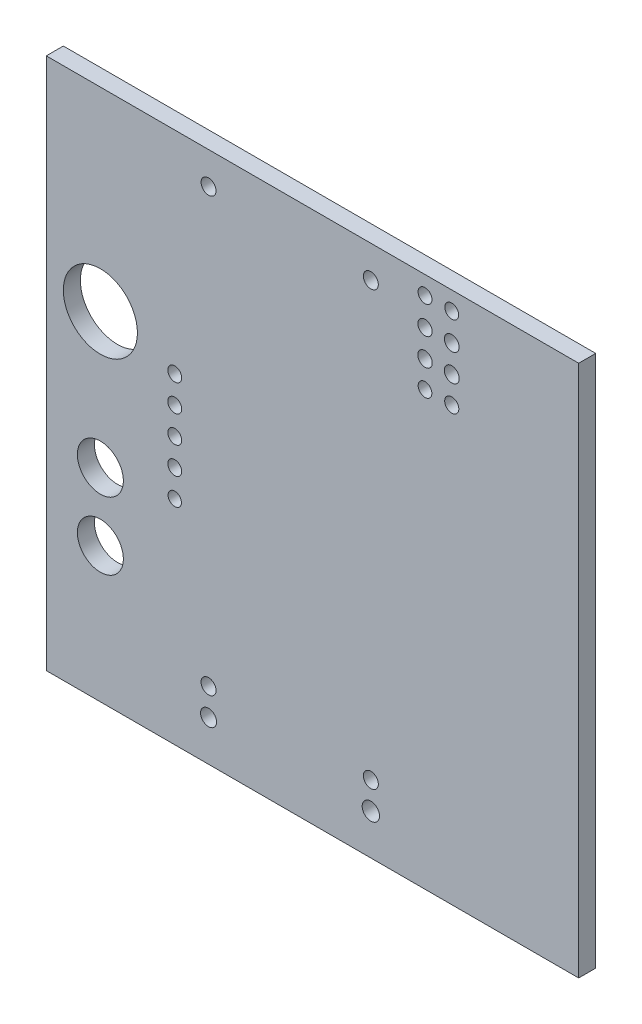
from build123d import *

# Parameters (mm, degrees)
ESQUISSE2_W             = 50
ESQUISSE2_H             = 50
ESQUISSE2_R             = 0.653993728
ESQUISSE2_R_2           = 0.692988534
ESQUISSE2_R_3           = 0.700788253
ESQUISSE2_R_4           = 0.663824111
ESQUISSE2_R_5           = 0.643645309
ESQUISSE2_R_6           = 0.680609451
ESQUISSE2_R_7           = 0.672816827
ESQUISSE2_R_8           = 0.653359991
ESQUISSE2_R_9           = 0.654
ESQUISSE2_R_10          = 0.628256736
ESQUISSE2_R_11          = 2.15927998
ESQUISSE2_R_12          = 2.159041941
ESQUISSE2_R_13          = 3.4798
ESQUISSE2_R_14          = 0.704
BOSS_EXTRU_1_DEPTH      = 1.6
ENL_V_MAT_EXTRU_1_REACH = 3.6
ESQUISSE3_R             = 0.75
ESQUISSE3_R_2           = 0.81381708


with BuildPart() as part:
    # Esquisse2 → Boss.-Extru.1 (new body)
    with BuildSketch(Plane.XY):
        with Locations((25, 25)):
            Rectangle(ESQUISSE2_W, ESQUISSE2_H)
        with Locations((38.078780302, 48.281219698)):
            Circle(ESQUISSE2_R, mode=Mode.SUBTRACT)
        with Locations((38.078780302, 45.686072715)):
            Circle(ESQUISSE2_R_2, mode=Mode.SUBTRACT)
        with Locations((38.078780302, 43.135042247)):
            Circle(ESQUISSE2_R_3, mode=Mode.SUBTRACT)
        with Locations((38.078780302, 40.647317437)):
            Circle(ESQUISSE2_R_4, mode=Mode.SUBTRACT)
        with Locations((35.567317437, 40.647317437)):
            Circle(ESQUISSE2_R_5, mode=Mode.SUBTRACT)
        with Locations((35.567317437, 43.135042247)):
            Circle(ESQUISSE2_R_6, mode=Mode.SUBTRACT)
        with Locations((35.567317437, 45.686072715)):
            Circle(ESQUISSE2_R_7, mode=Mode.SUBTRACT)
        with Locations((35.567317437, 48.281219698)):
            Circle(ESQUISSE2_R_8, mode=Mode.SUBTRACT)
        with Locations((12.065, 22.5425)):
            Circle(ESQUISSE2_R_9, mode=Mode.SUBTRACT)
        with Locations((12.065, 25.0825)):
            Circle(ESQUISSE2_R_9, mode=Mode.SUBTRACT)
        with Locations((12.065, 27.6225)):
            Circle(ESQUISSE2_R_9, mode=Mode.SUBTRACT)
        with Locations((12.065, 30.1625)):
            Circle(ESQUISSE2_R_9, mode=Mode.SUBTRACT)
        with Locations((12.065, 20.0025)):
            Circle(ESQUISSE2_R_10, mode=Mode.SUBTRACT)
        with Locations((5.080184549, 19.049739168)):
            Circle(ESQUISSE2_R_11, mode=Mode.SUBTRACT)
        with Locations((5.080055874, 12.699958299)):
            Circle(ESQUISSE2_R_12, mode=Mode.SUBTRACT)
        with Locations((5.08, 31.75)):
            Circle(ESQUISSE2_R_13, mode=Mode.SUBTRACT)
        with Locations((15.24, 6.35)):
            Circle(ESQUISSE2_R_14, mode=Mode.SUBTRACT)
        with Locations((30.48, 6.35)):
            Circle(ESQUISSE2_R_14, mode=Mode.SUBTRACT)
        with Locations((15.24, 46.99)):
            Circle(ESQUISSE2_R_14, mode=Mode.SUBTRACT)
        with Locations((30.48, 46.99)):
            Circle(ESQUISSE2_R_14, mode=Mode.SUBTRACT)
    extrude(amount=BOSS_EXTRU_1_DEPTH)

    # Esquisse3 → Enlèv. mat.-Extru.1 (cut, up to next)
    with BuildSketch(Plane(origin=(0, 0, 0), x_dir=(-1, 0, 0), z_dir=(0, 0, -1)), mode=Mode.PRIVATE) as enl_v_mat_extru_1_sk1:
        with Locations((-15.24, 3.81)):
            Circle(ESQUISSE3_R)
    enl_v_mat_extru_1_tool1 = extrude(enl_v_mat_extru_1_sk1.sketch, amount=-ENL_V_MAT_EXTRU_1_REACH, mode=Mode.PRIVATE) & part.part
    add(enl_v_mat_extru_1_tool1.solids().sort_by_distance((15.24, 3.81, 0))[0], mode=Mode.SUBTRACT)
    # Esquisse3 → Enlèv. mat.-Extru.1 (cut, up to next)
    with BuildSketch(Plane(origin=(0, 0, 0), x_dir=(-1, 0, 0), z_dir=(0, 0, -1)), mode=Mode.PRIVATE) as enl_v_mat_extru_1_sk2:
        with Locations((-30.48, 3.81)):
            Circle(ESQUISSE3_R_2)
    enl_v_mat_extru_1_tool2 = extrude(enl_v_mat_extru_1_sk2.sketch, amount=-ENL_V_MAT_EXTRU_1_REACH, mode=Mode.PRIVATE) & part.part
    add(enl_v_mat_extru_1_tool2.solids().sort_by_distance((30.48, 3.81, 0))[0], mode=Mode.SUBTRACT)


solid = part.part
